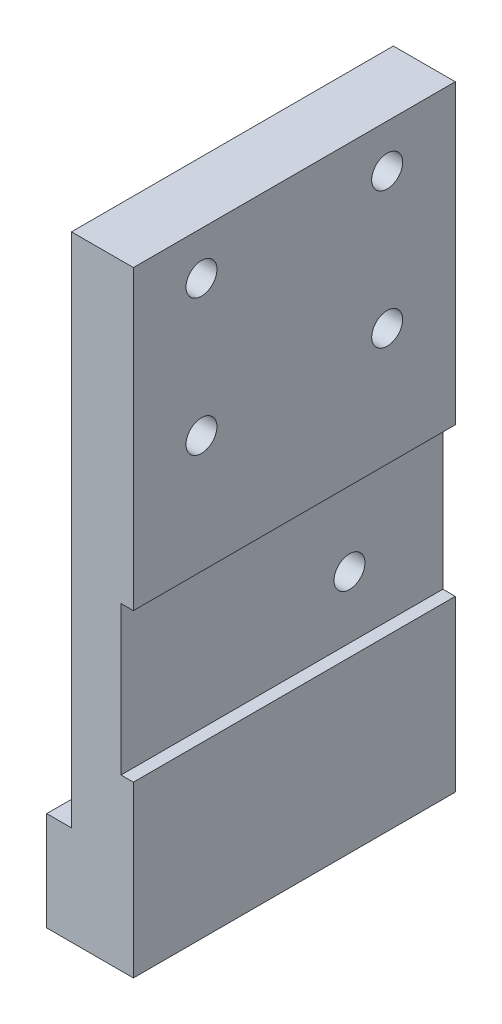
from build123d import *

# Parameters (mm, degrees)
SKETCH_1_W             = 30
SKETCH_1_H             = 6
EXTRUDE_1_DEPTH        = 5
SKETCH_2_R             = 2.25
CUT_EXTRUDE_1_DEPTH    = 6
SKETCH_3_W             = 40
SKETCH_3_H             = 30
EXTRUDE_2_DEPTH        = 5
SKETCH_4_W             = 3
SKETCH_4_H             = 20
CUT_EXTRUDE_2_DEPTH    = 10
SKETCH_7_W             = 10
SKETCH_7_H             = 5
CUT_EXTRUDE_3_DEPTH    = 31
SKETCH_9_W             = 5
SKETCH_9_H             = 5
EXTRUDE_5_DEPTH        = 18
SKETCH_10_W            = 10
SKETCH_10_H            = 20
CUT_EXTRUDE_4_DEPTH    = 18
SKETCH_11_W            = 17
SKETCH_11_H            = 5
EXTRUDE_6_DEPTH        = 0.7
SKETCH_12_W            = 5
SKETCH_12_H            = 5
EXTRUDE_7_DEPTH        = 0.7
SKETCH_13_W            = 26
SKETCH_13_H            = 18
EXTRUDE_8_DEPTH        = 5
HOLE_WIZARD_M3_1_D     = 2.5
HOLE_WIZARD_M3_1_DEPTH = 7.5
HOLE_WIZARD_M3_1_TIP   = 0.751075774
SKETCH_16_W            = 14.26711197
SKETCH_16_H            = 39.299316136
CUT_EXTRUDE_5_DEPTH    = 31
SKETCH_17_W            = 5
SKETCH_17_H            = 26
EXTRUDE_9_DEPTH        = 30.7
SKETCH_18_W            = 5
SKETCH_18_H            = 26
EXTRUDE_10_DEPTH       = 1
SKETCH_20_W            = 26
SKETCH_20_H            = 8
EXTRUDE_11_DEPTH       = 2
HOLE_WIZARD_M4_1_D     = 3.3
HOLE_WIZARD_M4_1_DEPTH = 6
HOLE_WIZARD_M4_1_TIP   = 0.991420021
SKETCH_23_W            = 26
SKETCH_23_H            = 12
CUT_EXTRUDE_6_DEPTH    = 1
HOLE_WIZARD_M3_2_D     = 2.5
HOLE_WIZARD_M3_2_DEPTH = 7.5
HOLE_WIZARD_M3_2_TIP   = 0.751075774


with BuildPart() as part:
    # 草图1 → 凸台-拉伸1 (new body)
    with BuildSketch(Plane.XY):
        with Locations((15, 3)):
            Rectangle(SKETCH_1_W, SKETCH_1_H)
    extrude(amount=EXTRUDE_1_DEPTH)

    # 草图2 → 切除-拉伸1 (cut, through all)
    with BuildSketch(Plane.XY.offset(5)):
        with Locations((22.5, 3)):
            Circle(SKETCH_2_R)
        with Locations((7.5, 3)):
            Circle(SKETCH_2_R)
    extrude(amount=-CUT_EXTRUDE_1_DEPTH, mode=Mode.SUBTRACT)

    # 草图3 → 凸台-拉伸2 (add)
    with BuildSketch(Plane.XY.offset(5)):
        with Locations((10, 21)):
            Rectangle(SKETCH_3_W, SKETCH_3_H)
    extrude(amount=-EXTRUDE_2_DEPTH)

    # 草图4 → 切除-拉伸2 (cut)
    with BuildSketch(Plane.XY.offset(5)):
        with Locations((28.5, 26)):
            Rectangle(SKETCH_4_W, SKETCH_4_H)
    extrude(amount=-CUT_EXTRUDE_2_DEPTH, mode=Mode.SUBTRACT)

    # 草图7 → 切除-拉伸3 (cut, through all)
    with BuildSketch(Plane.XZ.offset(-6)):
        with Locations((-5, 2.5)):
            Rectangle(SKETCH_7_W, SKETCH_7_H)
    extrude(amount=-CUT_EXTRUDE_3_DEPTH, mode=Mode.SUBTRACT)

    # 草图9 → 凸台-拉伸5 (add)
    with BuildSketch(Plane(origin=(0, 36, 0), x_dir=(1, 0, 0), z_dir=(0, 1, 0))):
        with Locations((19.9, -2.5)):
            Rectangle(SKETCH_9_W, SKETCH_9_H)
    extrude(amount=EXTRUDE_5_DEPTH)

    # 草图10 → 切除-拉伸4 (cut)
    with BuildSketch(Plane.XY.offset(5)):
        with Locations((5, 26)):
            Rectangle(SKETCH_10_W, SKETCH_10_H)
    extrude(amount=-CUT_EXTRUDE_4_DEPTH, mode=Mode.SUBTRACT)

    # 草图11 → 凸台-拉伸6 (add)
    with BuildSketch(Plane(origin=(0, 36, 0), x_dir=(1, 0, 0), z_dir=(0, 1, 0))):
        with Locations((18.5, -2.5)):
            Rectangle(SKETCH_11_W, SKETCH_11_H)
    extrude(amount=EXTRUDE_6_DEPTH)

    # 草图12 → 凸台-拉伸7 (add)
    with BuildSketch(Plane(origin=(0, 54, 0), x_dir=(1, 0, 0), z_dir=(0, 1, 0))):
        with Locations((19.9, -2.5)):
            Rectangle(SKETCH_12_W, SKETCH_12_H)
    extrude(amount=EXTRUDE_7_DEPTH)

    # 草图13 → 凸台-拉伸8 (add)
    with BuildSketch(Plane.ZY.offset(-17.4)):
        with Locations((2.5, 45.7)):
            Rectangle(SKETCH_13_W, SKETCH_13_H)
    extrude(amount=-EXTRUDE_8_DEPTH)

    # M3 螺纹孔1
    with Locations(Plane(origin=(22.4, 0, 0), x_dir=(0, 0, -1), z_dir=(1, 0, 0))):
        with Locations((-10, 40.2), (5, 40.2), (5, 51.2), (-10, 51.2)):
            Hole(HOLE_WIZARD_M3_1_D / 2, depth=HOLE_WIZARD_M3_1_DEPTH)
            with Locations((0, 0, -(HOLE_WIZARD_M3_1_DEPTH + HOLE_WIZARD_M3_1_TIP / 2))):  # 118° drill point
                Cone(0, HOLE_WIZARD_M3_1_D / 2, HOLE_WIZARD_M3_1_TIP, mode=Mode.SUBTRACT)

    # 草图16 → 切除-拉伸5 (cut, through all)
    with BuildSketch(Plane(origin=(30, 0, 0), x_dir=(0, 0, -1), z_dir=(1, 0, 0))):
        with Locations((-7.133555985, 17.050341932)):
            Rectangle(SKETCH_16_W, SKETCH_16_H)
    extrude(amount=-CUT_EXTRUDE_5_DEPTH, mode=Mode.SUBTRACT)

    # 草图17 → 凸台-拉伸9 (add)
    with BuildSketch(Plane.XZ.offset(-36.7)):
        with Locations((19.9, 2.5)):
            Rectangle(SKETCH_17_W, SKETCH_17_H)
    extrude(amount=EXTRUDE_9_DEPTH)

    # 草图18 → 凸台-拉伸10 (add)
    with BuildSketch(Plane.XZ.offset(-6)):
        with Locations((19.9, 2.5)):
            Rectangle(SKETCH_18_W, SKETCH_18_H)
    extrude(amount=EXTRUDE_10_DEPTH)

    # 草图20 → 凸台-拉伸11 (add)
    with BuildSketch(Plane.ZY.offset(-17.4)):
        with Locations((2.5, 9)):
            Rectangle(SKETCH_20_W, SKETCH_20_H)
    extrude(amount=EXTRUDE_11_DEPTH)

    # M4 螺纹孔1
    with Locations(Plane(origin=(0, 5, 0), x_dir=(-1, 0, 0), z_dir=(0, -1, 0))):
        with Locations((-18.9, -7.640506964), (-18.9, 3.359493036)):
            Hole(HOLE_WIZARD_M4_1_D / 2, depth=HOLE_WIZARD_M4_1_DEPTH)
            with Locations((0, 0, -(HOLE_WIZARD_M4_1_DEPTH + HOLE_WIZARD_M4_1_TIP / 2))):  # 118° drill point
                Cone(0, HOLE_WIZARD_M4_1_D / 2, HOLE_WIZARD_M4_1_TIP, mode=Mode.SUBTRACT)

    # 草图23 → 切除-拉伸6 (cut)
    with BuildSketch(Plane(origin=(22.4, 0, 0), x_dir=(0, 0, -1), z_dir=(1, 0, 0))):
        with Locations((-2.5, 24.7)):
            Rectangle(SKETCH_23_W, SKETCH_23_H)
    extrude(amount=-CUT_EXTRUDE_6_DEPTH, mode=Mode.SUBTRACT)

    # M3 螺纹孔2
    with Locations(Plane(origin=(21.4, 0, 0), x_dir=(0, 0, -1), z_dir=(1, 0, 0))):
        with Locations((2.955672884, 23.7)):
            Hole(HOLE_WIZARD_M3_2_D / 2, depth=HOLE_WIZARD_M3_2_DEPTH)
            with Locations((0, 0, -(HOLE_WIZARD_M3_2_DEPTH + HOLE_WIZARD_M3_2_TIP / 2))):  # 118° drill point
                Cone(0, HOLE_WIZARD_M3_2_D / 2, HOLE_WIZARD_M3_2_TIP, mode=Mode.SUBTRACT)


solid = part.part
